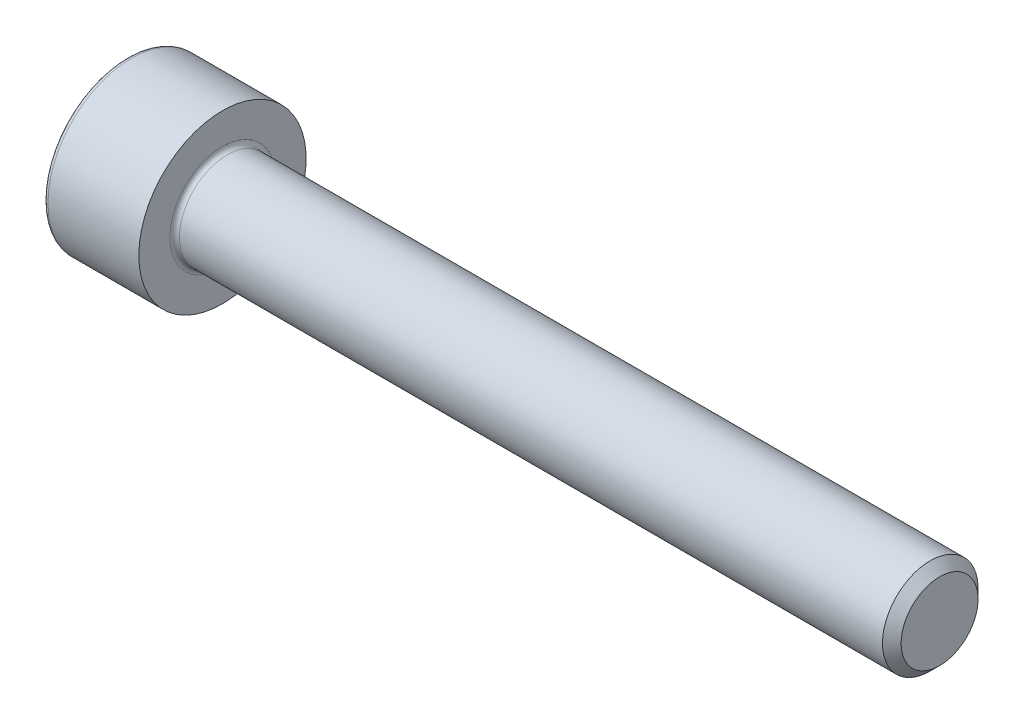
from build123d import *

# Parameters (mm, degrees)
FILLET1_R   = 0.2
FILLET2_R   = 0.2
HEX_2_DEPTH = 2


with BuildPart() as part:
    # BodySke → Base-Revolve (revolve)
    with BuildSketch(Plane.XY):
        Polygon((0, 0), (0, 3.5), (4, 3.5), (4, 2), (33.61, 2), (34, 1.61), (34, 0), align=None)
    revolve(axis=Axis((-31.75, 0, 0), (1, 0, 0)))

    # Fillet1
    fillet1_edges = [part.edges().sort_by_distance(p)[0] for p in [
        (4, -2, 0),
    ]]
    fillet(fillet1_edges, radius=FILLET1_R)

    # Fillet2
    fillet2_edges = [part.edges().sort_by_distance(p)[0] for p in [
        (0, -3.5, 0),
    ]]
    fillet(fillet2_edges, radius=FILLET2_R)

    # Sketch2 → Hex-PreBroach (revolve, cut)
    with BuildSketch(Plane.XY):
        Polygon((0, 1.5355), (2, 1.5355), (2.886521338, 0), (0, 0), align=None)
    revolve(axis=Axis((0, 0, 0), (1, 0, 0)), mode=Mode.SUBTRACT)

    # Sketch3 → Hex 2 (cut)
    with BuildSketch(Plane(origin=(0, 0, 0), x_dir=(0, 0.5, 0.866025404), z_dir=(-1, 0, 0))):
        Polygon((0.886521338, 1.5355), (-0.886521338, 1.5355), (-1.773042677, 0), (-0.886521338, -1.5355), (0.886521338, -1.5355), (1.773042677, 0), align=None)
    extrude(amount=-HEX_2_DEPTH, mode=Mode.SUBTRACT)


solid = part.part
